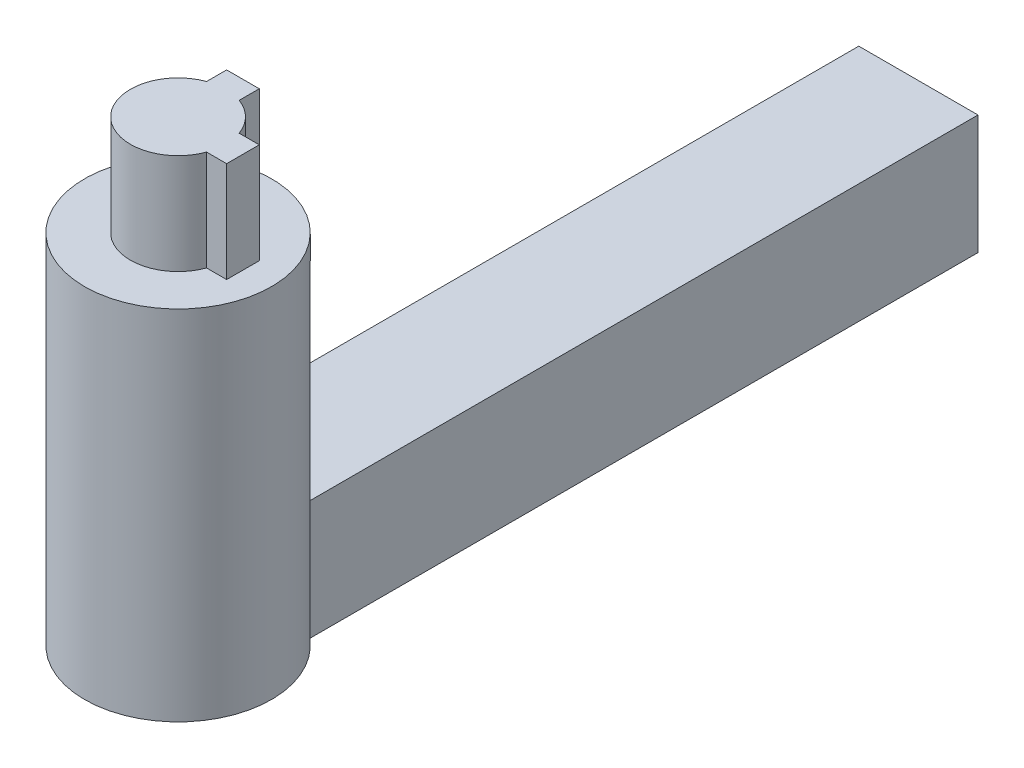
from build123d import *

# Parameters (mm, degrees)
SKETCH1_W                = 9.5
SKETCH1_H                = 59
BOSS_EXTRUDE1_DEPTH      = 9.5
SKETCH2_R                = 7.45
BOSS_EXTRUDE2_DEPTH      = 19
BOSS_EXTRUDE2_DEPTH_BACK = 9.5
BOSS_EXTRUDE3_DEPTH      = 8


with BuildPart() as part:
    # Sketch1 → Boss-Extrude1 (new body)
    with BuildSketch(Plane(origin=(0, 0, 0), x_dir=(1, 0, 0), z_dir=(0, 1, 0))):
        Rectangle(SKETCH1_W, SKETCH1_H)
    extrude(amount=BOSS_EXTRUDE1_DEPTH)

    # Sketch2 → Boss-Extrude2 (add, two sides)
    with BuildSketch(Plane(origin=(0, 9.5, 0), x_dir=(1, 0, 0), z_dir=(0, 1, 0))) as boss_extrude2_sk:
        with Locations((0, -29.5)):
            Circle(SKETCH2_R)
    extrude(amount=BOSS_EXTRUDE2_DEPTH)
    extrude(boss_extrude2_sk.sketch, amount=-BOSS_EXTRUDE2_DEPTH_BACK)

    # Sketch3 → Boss-Extrude3 (add)
    with BuildSketch(Plane(origin=(0, 28.5, 0), x_dir=(1, 0, 0), z_dir=(0, 1, 0))):
        with BuildLine():
            Line((-1.3, -25.929285786), (-1.3, -24.329285786))
            Line((-1.3, -24.329285786), (1.3, -24.329285786))
            Line((1.3, -24.329285786), (1.3, -25.929285786))
            ThreePointArc((1.3, -25.929285786), (2.687005769, -26.812994231), (3.570714214, -28.2))
            Line((3.570714214, -28.2), (5.170714214, -28.2))
            Line((5.170714214, -28.2), (5.170714214, -30.8))
            Line((5.170714214, -30.8), (3.570714214, -30.8))
            ThreePointArc((3.570714214, -30.8), (-2.687005769, -32.187005769), (-1.3, -25.929285786))
        make_face()
    extrude(amount=BOSS_EXTRUDE3_DEPTH)


solid = part.part
